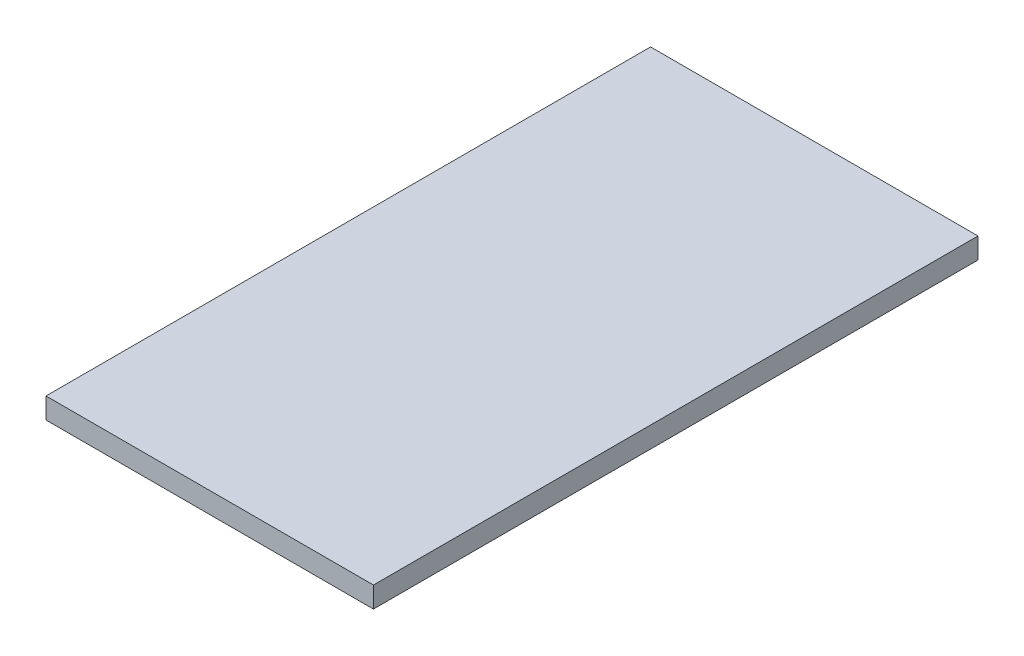
from build123d import *

# Parameters (mm, degrees)
SKETCH1_W           = 299.212
SKETCH1_H           = 552.45
BOSS_EXTRUDE1_DEPTH = 19.05


with BuildPart() as part:
    # Sketch1 → Boss-Extrude1 (new body)
    with BuildSketch(Plane(origin=(0, 0, 0), x_dir=(1, 0, 0), z_dir=(0, 1, 0))):
        with Locations((149.606, 276.225)):
            Rectangle(SKETCH1_W, SKETCH1_H)
    extrude(amount=-BOSS_EXTRUDE1_DEPTH)


solid = part.part
